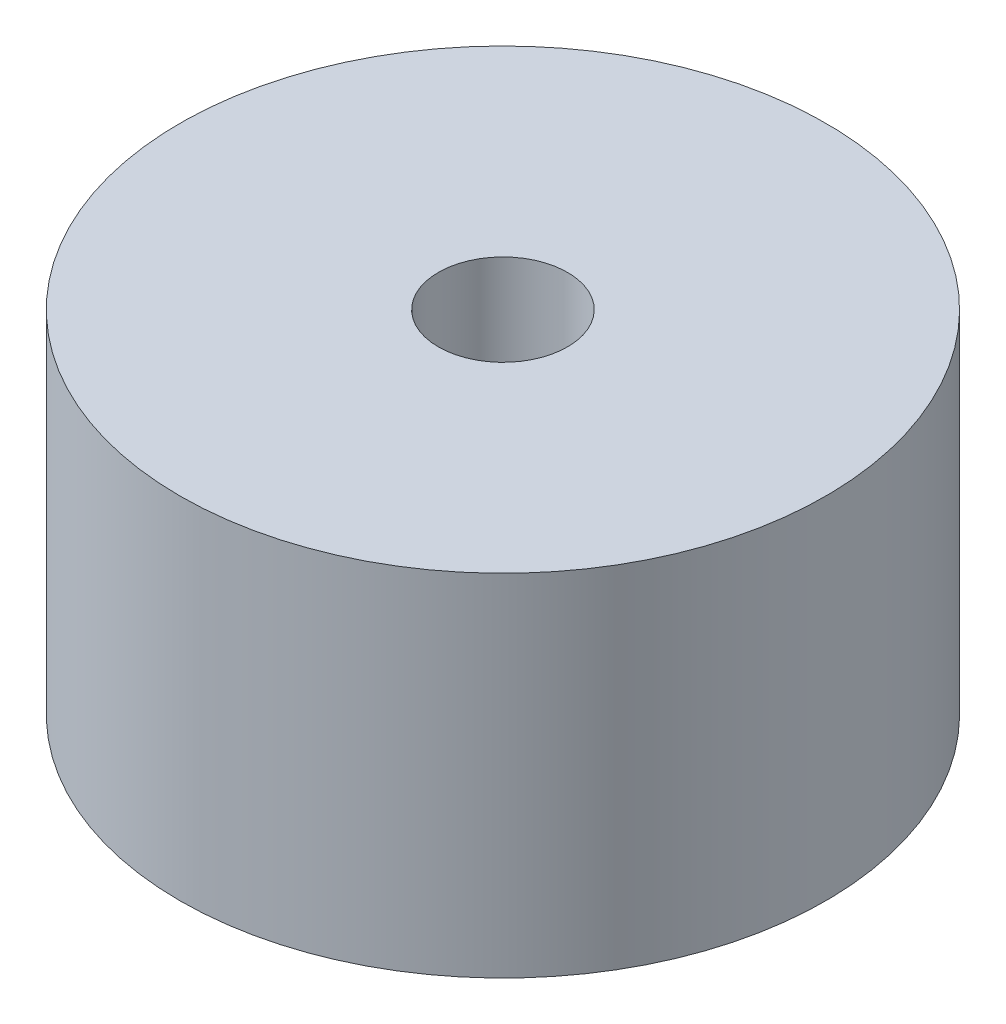
from build123d import *


with BuildPart() as part:
    # Sketch1 → Revolve1 (revolve)
    with BuildSketch(Plane.XY):
        Polygon((7, 30.326538871), (7, 10.326538871), (25, -7.673461129), (35, -7.673461129), (35, 30.326538871), align=None)
    revolve(axis=Axis((0, 50.568068379, 0), (0, -1, 0)))


solid = part.part
